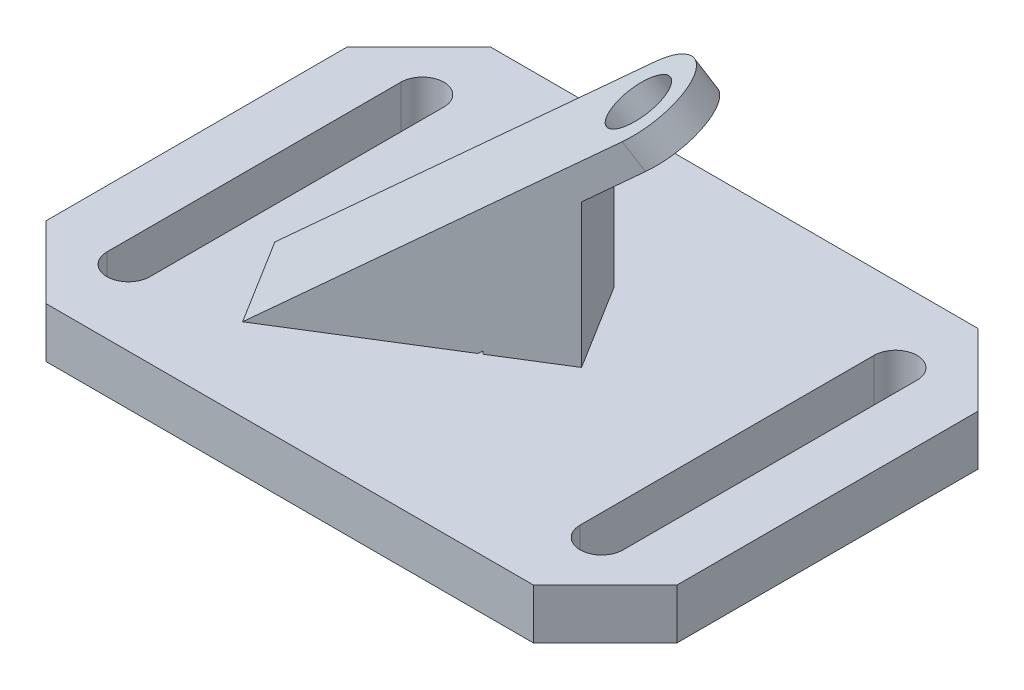
from build123d import *

# Parameters (mm, degrees)
BOSS_EXTRUDE1_DEPTH = 7
EXTRUDE_THIN1_DEPTH = 7
SKETCH4_R           = 4
BOSS_EXTRUDE2_DEPTH = 4


with BuildPart() as part:
    # Sketch1 → Boss-Extrude1 (new body)
    with BuildSketch(Plane(origin=(0, 0, 0), x_dir=(1, 0, 0), z_dir=(0, 1, 0))):
        Polygon((34, 31), (44, 21), (44, -21), (34, -31), (-34, -31), (-44, -21), (-44, 21), (-34, 31), align=None)
        with BuildLine():
            Line((-30, 20.5), (-30, -20.5))
            ThreePointArc((-30, -20.5), (-33, -23.5), (-36, -20.5))
            Line((-36, -20.5), (-36, 20.5))
            ThreePointArc((-36, 20.5), (-33, 23.5), (-30, 20.5))
        make_face(mode=Mode.SUBTRACT)
        with BuildLine():
            Line((36, 20.5), (36, -20.5))
            ThreePointArc((36, -20.5), (33, -23.5), (30, -20.5))
            Line((30, -20.5), (30, 20.5))
            ThreePointArc((30, 20.5), (33, 23.5), (36, 20.5))
        make_face(mode=Mode.SUBTRACT)
    extrude(amount=BOSS_EXTRUDE1_DEPTH)

    # Sketch3 → Extrude-Thin1 (add, symmetric)
    with BuildSketch(Plane(origin=(0, 0, 0), x_dir=(0.849441251, 0, -0.527683201), z_dir=(0.527683201, 0, 0.849441251))):
        Polygon((-18.849066913, 7), (8.678571497, 27), (8.678571497, 7), (-1.321428503, 7), (-1.321428503, 7.373894945), (-12.97121439, -1.090169944), align=None)
    extrude(amount=EXTRUDE_THIN1_DEPTH, both=True)

    # Sketch4 → Boss-Extrude2 (add)
    with BuildSketch(Plane(origin=(-8.359258135, 13.544823437, 5.192872478), x_dir=(0.866435488, 0.466201263, 0.178734239), z_dir=(-0.49928904, 0.809016994, 0.310164404))):
        with BuildLine():
            Line((20.238219538, 24.365708041), (-17.853578159, -4.883475366))
            Line((-17.853578159, -4.883475366), (-9.327190536, -15.987560835))
            Line((-9.327190536, -15.987560835), (28.764607161, 13.261622572))
            ThreePointArc((28.764607161, 13.261622572), (30.053456084, 23.076859118), (20.238219538, 24.365708041))
        make_face()
        with Locations((24.501413349, 18.813665306)):
            Circle(SKETCH4_R, mode=Mode.SUBTRACT)
    extrude(amount=BOSS_EXTRUDE2_DEPTH)


solid = part.part
